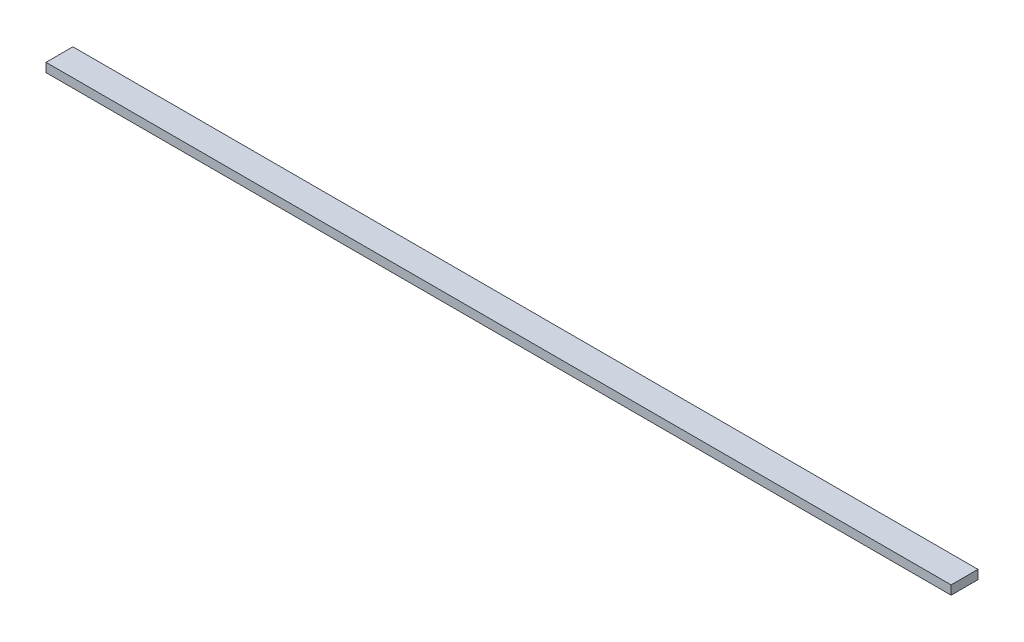
from build123d import *

# Parameters (mm, degrees)
SKETCH1_W           = 1010
SKETCH1_H           = 30
BOSS_EXTRUDE1_DEPTH = 10


with BuildPart() as part:
    # Sketch1 → Boss-Extrude1 (new body)
    with BuildSketch(Plane(origin=(0, 0, 0), x_dir=(1, 0, 0), z_dir=(0, 1, 0))):
        Rectangle(SKETCH1_W, SKETCH1_H)
    extrude(amount=BOSS_EXTRUDE1_DEPTH)


solid = part.part
